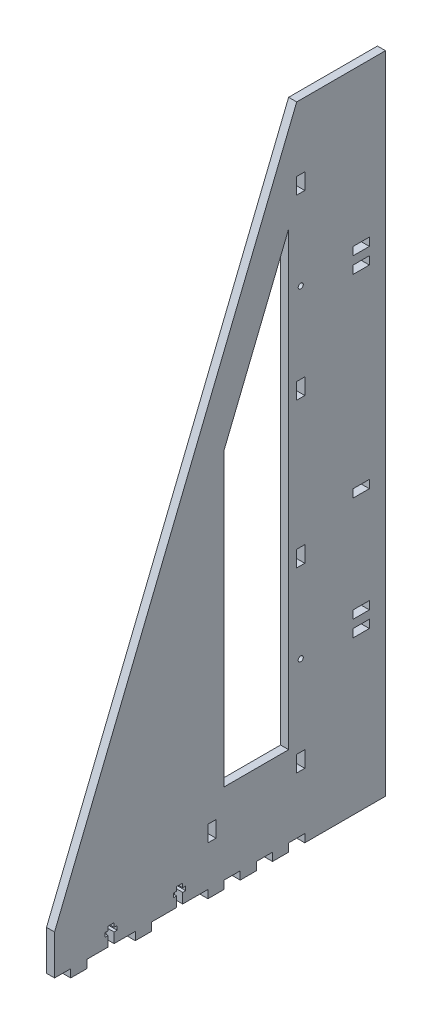
from build123d import *

# Parameters (mm, degrees)
BOSS_EXTRUDE1_DEPTH = 6.35
CUT_EXTRUDE1_DEPTH  = 6.35
SKETCH5_R           = 2
SKETCH5_W           = 6.35
SKETCH5_H           = 12.7
SKETCH5_W_2         = 12.7
SKETCH5_H_2         = 6.35
CUT_EXTRUDE2_DEPTH  = 6.35
SKETCH6_W           = 6.35
SKETCH6_H           = 12.7
CUT_EXTRUDE3_DEPTH  = 6.35
SKETCH7_W           = 12.7
SKETCH7_H           = 6.35
CUT_EXTRUDE4_DEPTH  = 6.35


with BuildPart() as part:
    # Sketch1 → Boss-Extrude1 (new body)
    with BuildSketch(Plane(origin=(0, 0, 0), x_dir=(0, 0, -1), z_dir=(1, 0, 0))):
        Polygon((12.7, 6.35), (12.7, 0), (25.4, 0), (25.4, 6.35), (63.5, 6.35), (63.5, 0), (76.2, 0), (76.2, 6.35), (120.65, 6.35), (120.65, 0), (133.35, 0), (133.35, 6.35), (146.05, 6.35), (146.05, 0), (158.75, 0), (158.75, 6.35), (171.45, 6.35), (171.45, 0), (176.749457482, 0), (184.15, 0), (184.15, 6.35), (196.85, 6.35), (196.85, 0), (260.35, 0), (260.35, 508), (190.5, 508), (0, 37.703125), (0, 6.35), align=None)
        Polygon((133.35, 299.255680579), (184.15, 424.668180579), (184.15, 69.85), (133.35, 69.85), (133.35, 274.095300459), align=None, mode=Mode.SUBTRACT)
    extrude(amount=BOSS_EXTRUDE1_DEPTH)

    # Sketch3 → Cut-Extrude1 (cut)
    with BuildSketch(Plane(origin=(6.35, 0, 0), x_dir=(0, 0, -1), z_dir=(1, 0, 0))):
        Polygon((49.2125, 17.4625), (49.2125, 14.2875), (46.83125, 14.2875), (46.83125, 6.35), (42.06875, 6.35), (42.06875, 14.2875), (39.6875, 14.2875), (39.6875, 17.4625), (42.06875, 17.4625), (42.06875, 20.6375), (46.83125, 20.6375), (46.83125, 17.4625), align=None)
        Polygon((103.1875, 17.4625), (103.1875, 14.2875), (100.80625, 14.2875), (100.80625, 6.35), (96.04375, 6.35), (96.04375, 14.2875), (93.6625, 14.2875), (93.6625, 17.4625), (96.04375, 17.4625), (96.04375, 20.6375), (100.80625, 20.6375), (100.80625, 17.4625), align=None)
    extrude(amount=-CUT_EXTRUDE1_DEPTH, mode=Mode.SUBTRACT)

    # Sketch5 → Cut-Extrude2 (cut)
    with BuildSketch(Plane(origin=(6.35, 0, 0), x_dir=(0, 0, -1), z_dir=(1, 0, 0))):
        with Locations((193.675, 127)):
            Circle(SKETCH5_R)
        with Locations((193.675, 381)):
            Circle(SKETCH5_R)
        with Locations((193.675, 57.15)):
            Rectangle(SKETCH5_W, SKETCH5_H)
        with Locations((193.675, 196.85)):
            Rectangle(SKETCH5_W, SKETCH5_H)
        with Locations((241.3, 371.475)):
            Rectangle(SKETCH5_W_2, SKETCH5_H_2)
        with Locations((241.3, 123.825)):
            Rectangle(SKETCH5_W_2, SKETCH5_H_2)
        with Locations((241.3, 136.525)):
            Rectangle(SKETCH5_W_2, SKETCH5_H_2)
        with Locations((241.3, 384.175)):
            Rectangle(SKETCH5_W_2, SKETCH5_H_2)
        with Locations((193.675, 311.15)):
            Rectangle(SKETCH5_W, SKETCH5_H)
        with Locations((193.675, 450.85)):
            Rectangle(SKETCH5_W, SKETCH5_H)
    extrude(amount=-CUT_EXTRUDE2_DEPTH, mode=Mode.SUBTRACT)

    # Sketch6 → Cut-Extrude3 (cut)
    with BuildSketch(Plane(origin=(6.35, 0, 0), x_dir=(0, 0, -1), z_dir=(1, 0, 0))):
        with Locations((123.825, 44.45)):
            Rectangle(SKETCH6_W, SKETCH6_H)
    extrude(amount=-CUT_EXTRUDE3_DEPTH, mode=Mode.SUBTRACT)

    # Sketch7 → Cut-Extrude4 (cut)
    with BuildSketch(Plane(origin=(6.35, 0, 0), x_dir=(0, 0, -1), z_dir=(1, 0, 0))):
        with Locations((241.3, 219.075)):
            Rectangle(SKETCH7_W, SKETCH7_H)
    extrude(amount=-CUT_EXTRUDE4_DEPTH, mode=Mode.SUBTRACT)


solid = part.part
